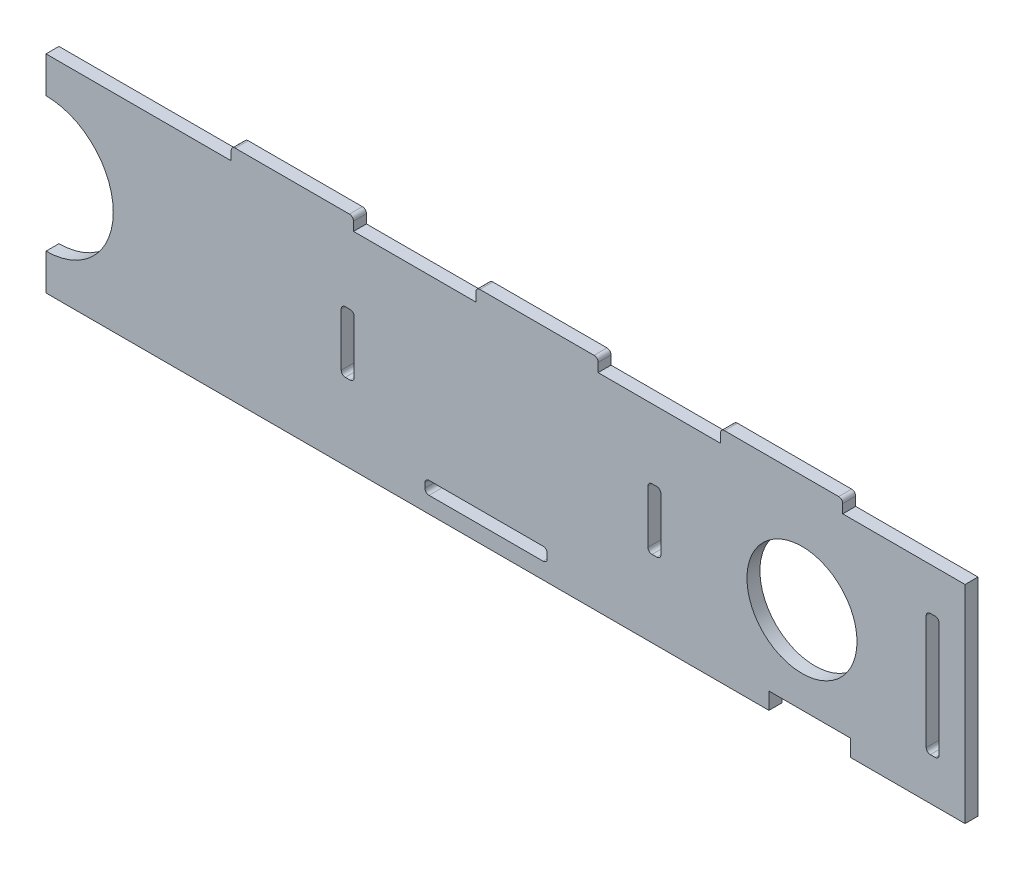
from build123d import *

# Parameters (mm, degrees)
SKETCH1_W           = 225.425
SKETCH1_H           = 50.8
BOSS_EXTRUDE1_DEPTH = 3.175
SKETCH2_W           = 30
SKETCH2_H           = 3.175
BOSS_EXTRUDE2_DEPTH = 3.175
SKETCH3_R           = 13.5
SKETCH3_R_2         = 16.5
CUT_EXTRUDE1_DEPTH  = 4.175
SKETCH4_W           = 3.175
SKETCH4_H           = 30
CUT_EXTRUDE2_DEPTH  = 10
SKETCH5_W           = 30
SKETCH5_H           = 3.175
CUT_EXTRUDE3_DEPTH  = 4.175
SKETCH6_W           = 3.175
SKETCH6_H           = 15
CUT_EXTRUDE4_DEPTH  = 4.175
SKETCH7_W           = 20
SKETCH7_H           = 4.111240443
CUT_EXTRUDE5_DEPTH  = 4.175
FILLET1_R           = 1


with BuildPart() as part:
    # Sketch1 → Boss-Extrude1 (new body)
    with BuildSketch(Plane.XY):
        Rectangle(SKETCH1_W, SKETCH1_H)
    extrude(amount=BOSS_EXTRUDE1_DEPTH)

    # Sketch2 → Boss-Extrude2 (add)
    with BuildSketch(Plane(origin=(0, 25.4, 0), x_dir=(1, 0, 0), z_dir=(0, 1, 0))):
        with Locations((67.7125, -1.5875)):
            Rectangle(SKETCH2_W, SKETCH2_H)
        with Locations((7.7125, -1.5875)):
            Rectangle(SKETCH2_W, SKETCH2_H)
        with Locations((-52.2875, -1.5875)):
            Rectangle(SKETCH2_W, SKETCH2_H)
    extrude(amount=BOSS_EXTRUDE2_DEPTH)

    # Sketch3 → Cut-Extrude1 (cut, through all)
    with BuildSketch(Plane.XY.offset(3.175)):
        with Locations((72.7125, 0)):
            Circle(SKETCH3_R)
        with Locations((-112.7125, 0)):
            Circle(SKETCH3_R_2)
    extrude(amount=-CUT_EXTRUDE1_DEPTH, mode=Mode.SUBTRACT)

    # Sketch4 → Cut-Extrude2 (cut)
    with BuildSketch(Plane.XY.offset(3.175)):
        with Locations((104.775, 0)):
            Rectangle(SKETCH4_W, SKETCH4_H)
    extrude(amount=-CUT_EXTRUDE2_DEPTH, mode=Mode.SUBTRACT)

    # Sketch5 → Cut-Extrude3 (cut, through all)
    with BuildSketch(Plane.XY.offset(3.175)):
        with Locations((-4.77, -19.8125)):
            Rectangle(SKETCH5_W, SKETCH5_H)
    extrude(amount=-CUT_EXTRUDE3_DEPTH, mode=Mode.SUBTRACT)

    # Sketch6 → Cut-Extrude4 (cut, through all)
    with BuildSketch(Plane.XY.offset(3.175)):
        with Locations((-38.7125, 0.9)):
            Rectangle(SKETCH6_W, SKETCH6_H)
        with Locations((36.5125, 0.9)):
            Rectangle(SKETCH6_W, SKETCH6_H)
    extrude(amount=-CUT_EXTRUDE4_DEPTH, mode=Mode.SUBTRACT)

    # Sketch7 → Cut-Extrude5 (cut, through all)
    with BuildSketch(Plane.XY.offset(3.175)):
        with Locations((74.6125, -23.344379779)):
            Rectangle(SKETCH7_W, SKETCH7_H)
    extrude(amount=-CUT_EXTRUDE5_DEPTH, mode=Mode.SUBTRACT)

    # Fillet1
    fillet1_edges = [part.edges().sort_by_distance(p)[0] for p in [
        (10.23, -18.225, 1.5875),
        (10.23, -21.4, 1.5875),
        (-19.77, -21.4, 1.5875),
        (-19.77, -18.225, 1.5875),
        (-37.125, 8.4, 1.5875),
        (-37.125, -6.6, 1.5875),
        (-40.3, -6.6, 1.5875),
        (-40.3, 8.4, 1.5875),
        (34.925, -6.6, 1.5875),
        (34.925, 8.4, 1.5875),
        (38.1, 8.4, 1.5875),
        (38.1, -6.6, 1.5875),
        (82.7125, 28.575, 1.5875),
        (52.7125, 28.575, 1.5875),
        (-7.2875, 28.575, 1.5875),
        (22.7125, 28.575, 1.5875),
        (-67.2875, 28.575, 1.5875),
        (-37.2875, 28.575, 1.5875),
        (103.1875, -15, 1.5875),
        (103.1875, 15, 1.5875),
        (106.3625, 15, 1.5875),
        (106.3625, -15, 1.5875),
    ]]
    fillet(fillet1_edges, radius=FILLET1_R)


solid = part.part
